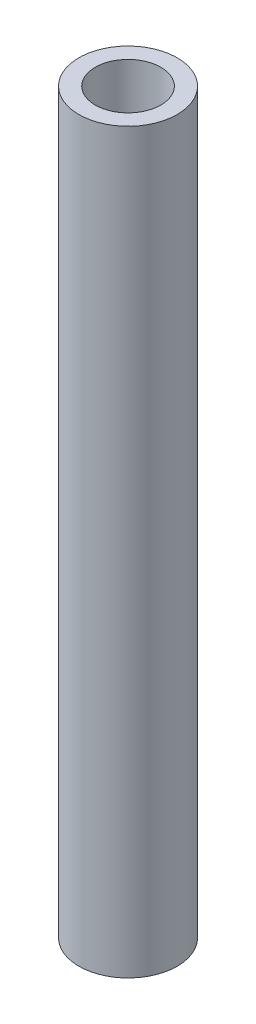
from build123d import *

# Parameters (mm, degrees)
CROQUIS1_W = 1
CROQUIS1_H = 45


with BuildPart() as part:
    # Croquis1 → Revolución1 (revolve)
    with BuildSketch(Plane.XY):
        with Locations((-2.5, 0)):
            Rectangle(CROQUIS1_W, CROQUIS1_H)
    revolve(axis=Axis((0, -0.720216084, 0), (0, 1, 0)))


solid = part.part
